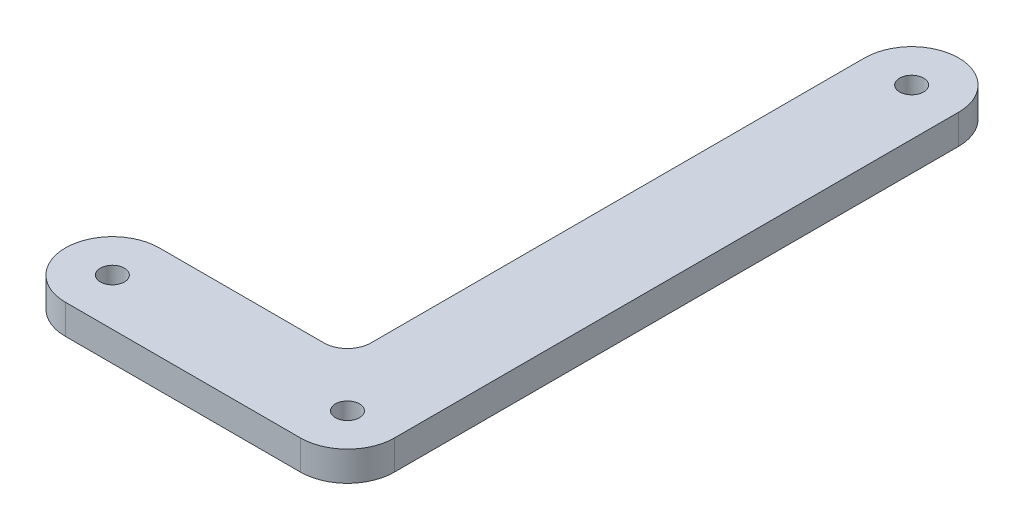
from build123d import *

# Parameters (mm, degrees)
SKETCH1_R           = 1.625
BOSS_EXTRUDE1_DEPTH = 4


with BuildPart() as part:
    # Sketch1 → Boss-Extrude1 (new body)
    with BuildSketch(Plane(origin=(0, 0, 0), x_dir=(1, 0, 0), z_dir=(0, 1, 0))):
        with BuildLine():
            Line((-18.618446602, -6.35), (13.131553398, -6.35))
            ThreePointArc((13.131553398, -6.35), (17.621681459, -4.490128061), (19.481553398, 0))
            Line((19.481553398, 0), (19.481553398, 76.2))
            ThreePointArc((19.481553398, 76.2), (13.131553398, 82.55), (6.781553398, 76.2))
            Line((6.781553398, 76.2), (6.781553398, 9.525))
            ThreePointArc((6.781553398, 9.525), (5.851617428, 7.27993597), (3.606553398, 6.35))
            Line((3.606553398, 6.35), (-18.618446602, 6.35))
            ThreePointArc((-18.618446602, 6.35), (-24.968446602, 0), (-18.618446602, -6.35))
        make_face()
        with Locations((-18.618446602, 0)):
            Circle(SKETCH1_R, mode=Mode.SUBTRACT)
        with Locations((13.131553398, 0)):
            Circle(SKETCH1_R, mode=Mode.SUBTRACT)
        with Locations((13.131553398, 76.2)):
            Circle(SKETCH1_R, mode=Mode.SUBTRACT)
    extrude(amount=BOSS_EXTRUDE1_DEPTH)


solid = part.part
